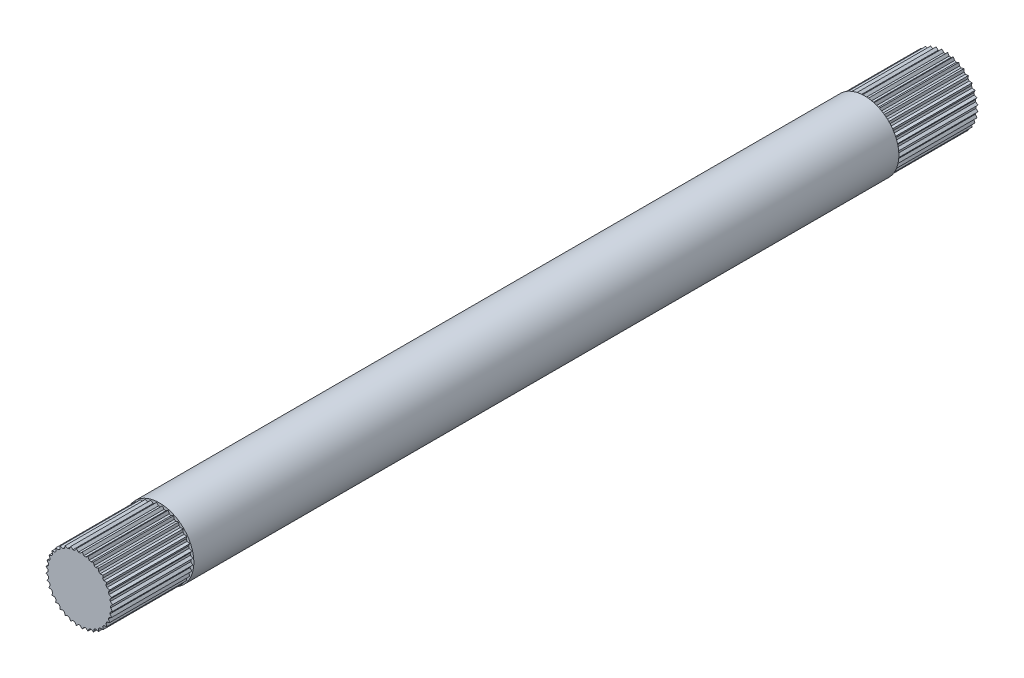
from build123d import *

# Parameters (mm, degrees)
SKETCH5_W           = 1.587499994
SKETCH5_H           = 239.930081988
CUT_EXTRUDE7_START  = 262.091582
SKETCH8_R           = 12.7
CUT_EXTRUDE7_DEPTH  = 22.225
SKETCH10_R          = 7.9375
BOSS_EXTRUDE1_DEPTH = 214.530082
CUT_EXTRUDE8_START  = 22.1615
SKETCH12_R          = 12.7
CUT_EXTRUDE8_DEPTH  = 22.225


with BuildPart() as part:
    # Sketch5 → Revolve2 (revolve)
    with BuildSketch(Plane(origin=(0, 0, 0), x_dir=(1, 0, 0), z_dir=(0, 1, 0))):
        with Locations((8.731249997, -142.126540994)):
            Rectangle(SKETCH5_W, SKETCH5_H)
    revolve(axis=Axis((0, 0, 0), (0, 0, 1)))

    # Sketch8 → Cut-Extrude7 (cut)
    with BuildSketch(Plane.XY.offset(CUT_EXTRUDE7_START)):
        Circle(SKETCH8_R)
        Polygon((9.235721046, -0.808020891), (8.681700155, -0.254), (8.681700155, 0.254), (9.235721046, 0.808020891), (8.593912259, 1.257420242), (8.505698985, 1.75770258), (8.955098336, 2.399511367), (8.245002688, 2.730634406), (8.071256455, 3.207998257), (8.402379494, 3.918093905), (7.645572882, 4.120879625), (7.391572882, 4.56082053), (7.594358603, 5.317627141), (6.813836213, 5.385914002), (6.487300108, 5.775064579), (6.555586968, 6.555586968), (5.775064579, 6.487300108), (5.385914002, 6.813836213), (5.317627141, 7.594358603), (4.56082053, 7.391572882), (4.120879625, 7.645572882), (3.918093905, 8.402379494), (3.207998257, 8.071256455), (2.730634406, 8.245002688), (2.399511367, 8.955098336), (1.75770258, 8.505698985), (1.257420242, 8.593912259), (0.808020891, 9.235721046), (0.254, 8.681700155), (-0.254, 8.681700155), (-0.808020891, 9.235721046), (-1.257420242, 8.593912259), (-1.75770258, 8.505698985), (-2.399511367, 8.955098336), (-2.730634406, 8.245002688), (-3.207998257, 8.071256455), (-3.918093905, 8.402379494), (-4.120879625, 7.645572882), (-4.56082053, 7.391572882), (-5.317627141, 7.594358603), (-5.385914002, 6.813836213), (-5.775064579, 6.487300108), (-6.555586968, 6.555586968), (-6.487300108, 5.775064579), (-6.813836213, 5.385914002), (-7.594358603, 5.317627141), (-7.391572882, 4.56082053), (-7.645572882, 4.120879625), (-8.402379494, 3.918093905), (-8.071256455, 3.207998257), (-8.245002688, 2.730634406), (-8.955098336, 2.399511367), (-8.505698985, 1.75770258), (-8.593912259, 1.257420242), (-9.235721046, 0.808020891), (-8.681700155, 0.254), (-8.681700155, -0.254), (-9.235721046, -0.808020891), (-8.593912259, -1.257420242), (-8.505698985, -1.75770258), (-8.955098336, -2.399511367), (-8.245002688, -2.730634406), (-8.071256455, -3.207998257), (-8.402379494, -3.918093905), (-7.645572882, -4.120879625), (-7.391572882, -4.56082053), (-7.594358603, -5.317627141), (-6.813836213, -5.385914002), (-6.487300108, -5.775064579), (-6.555586968, -6.555586968), (-5.775064579, -6.487300108), (-5.385914002, -6.813836213), (-5.317627141, -7.594358603), (-4.56082053, -7.391572882), (-4.120879625, -7.645572882), (-3.918093905, -8.402379494), (-3.207998257, -8.071256455), (-2.730634406, -8.245002688), (-2.399511367, -8.955098336), (-1.75770258, -8.505698985), (-1.257420242, -8.593912259), (-0.808020891, -9.235721046), (-0.254, -8.681700155), (0.254, -8.681700155), (0.808020891, -9.235721046), (1.257420242, -8.593912259), (1.75770258, -8.505698985), (2.399511367, -8.955098336), (2.730634406, -8.245002688), (3.207998257, -8.071256455), (3.918093905, -8.402379494), (4.120879625, -7.645572882), (4.56082053, -7.391572882), (5.317627141, -7.594358603), (5.385914002, -6.813836213), (5.775064579, -6.487300108), (6.555586968, -6.555586968), (6.487300108, -5.775064579), (6.813836213, -5.385914002), (7.594358603, -5.317627141), (7.391572882, -4.56082053), (7.645572882, -4.120879625), (8.402379494, -3.918093905), (8.071256455, -3.207998257), (8.245002688, -2.730634406), (8.955098336, -2.399511367), (8.505698985, -1.75770258), (8.593912259, -1.257420242), align=None, mode=Mode.SUBTRACT)
    extrude(amount=-CUT_EXTRUDE7_DEPTH, mode=Mode.SUBTRACT)

    # Sketch10 → Boss-Extrude1 (add)
    with BuildSketch(Plane(origin=(0, 0, 47.5615), x_dir=(-1, 0, 0), z_dir=(0, 0, -1))):
        Circle(SKETCH10_R)
    extrude(amount=-BOSS_EXTRUDE1_DEPTH)

    # Sketch12 → Cut-Extrude8 (cut)
    with BuildSketch(Plane.XY.offset(CUT_EXTRUDE8_START)):
        Circle(SKETCH12_R)
        Polygon((9.235721046, -0.808020891), (8.681700155, -0.254), (8.681700155, 0.254), (9.235721046, 0.808020891), (8.593912259, 1.257420242), (8.505698985, 1.75770258), (8.955098336, 2.399511367), (8.245002688, 2.730634406), (8.071256455, 3.207998257), (8.402379494, 3.918093905), (7.645572882, 4.120879625), (7.391572882, 4.56082053), (7.594358603, 5.317627141), (6.813836213, 5.385914002), (6.487300108, 5.775064579), (6.555586968, 6.555586968), (5.775064579, 6.487300108), (5.385914002, 6.813836213), (5.317627141, 7.594358603), (4.56082053, 7.391572882), (4.120879625, 7.645572882), (3.918093905, 8.402379494), (3.207998257, 8.071256455), (2.730634406, 8.245002688), (2.399511367, 8.955098336), (1.75770258, 8.505698985), (1.257420242, 8.593912259), (0.808020891, 9.235721046), (0.254, 8.681700155), (-0.254, 8.681700155), (-0.808020891, 9.235721046), (-1.257420242, 8.593912259), (-1.75770258, 8.505698985), (-2.399511367, 8.955098336), (-2.730634406, 8.245002688), (-3.207998257, 8.071256455), (-3.918093905, 8.402379494), (-4.120879625, 7.645572882), (-4.56082053, 7.391572882), (-5.317627141, 7.594358603), (-5.385914002, 6.813836213), (-5.775064579, 6.487300108), (-6.555586968, 6.555586968), (-6.487300108, 5.775064579), (-6.813836213, 5.385914002), (-7.594358603, 5.317627141), (-7.391572882, 4.56082053), (-7.645572882, 4.120879625), (-8.402379494, 3.918093905), (-8.071256455, 3.207998257), (-8.245002688, 2.730634406), (-8.955098336, 2.399511367), (-8.505698985, 1.75770258), (-8.593912259, 1.257420242), (-9.235721046, 0.808020891), (-8.681700155, 0.254), (-8.681700155, -0.254), (-9.235721046, -0.808020891), (-8.593912259, -1.257420242), (-8.505698985, -1.75770258), (-8.955098336, -2.399511367), (-8.245002688, -2.730634406), (-8.071256455, -3.207998257), (-8.402379494, -3.918093905), (-7.645572882, -4.120879625), (-7.391572882, -4.56082053), (-7.594358603, -5.317627141), (-6.813836213, -5.385914002), (-6.487300108, -5.775064579), (-6.555586968, -6.555586968), (-5.775064579, -6.487300108), (-5.385914002, -6.813836213), (-5.317627141, -7.594358603), (-4.56082053, -7.391572882), (-4.120879625, -7.645572882), (-3.918093905, -8.402379494), (-3.207998257, -8.071256455), (-2.730634406, -8.245002688), (-2.399511367, -8.955098336), (-1.75770258, -8.505698985), (-1.257420242, -8.593912259), (-0.808020891, -9.235721046), (-0.254, -8.681700155), (0.254, -8.681700155), (0.808020891, -9.235721046), (1.257420242, -8.593912259), (1.75770258, -8.505698985), (2.399511367, -8.955098336), (2.730634406, -8.245002688), (3.207998257, -8.071256455), (3.918093905, -8.402379494), (4.120879625, -7.645572882), (4.56082053, -7.391572882), (5.317627141, -7.594358603), (5.385914002, -6.813836213), (5.775064579, -6.487300108), (6.555586968, -6.555586968), (6.487300108, -5.775064579), (6.813836213, -5.385914002), (7.594358603, -5.317627141), (7.391572882, -4.56082053), (7.645572882, -4.120879625), (8.402379494, -3.918093905), (8.071256455, -3.207998257), (8.245002688, -2.730634406), (8.955098336, -2.399511367), (8.505698985, -1.75770258), (8.593912259, -1.257420242), align=None, mode=Mode.SUBTRACT)
    extrude(amount=CUT_EXTRUDE8_DEPTH, mode=Mode.SUBTRACT)


solid = part.part
